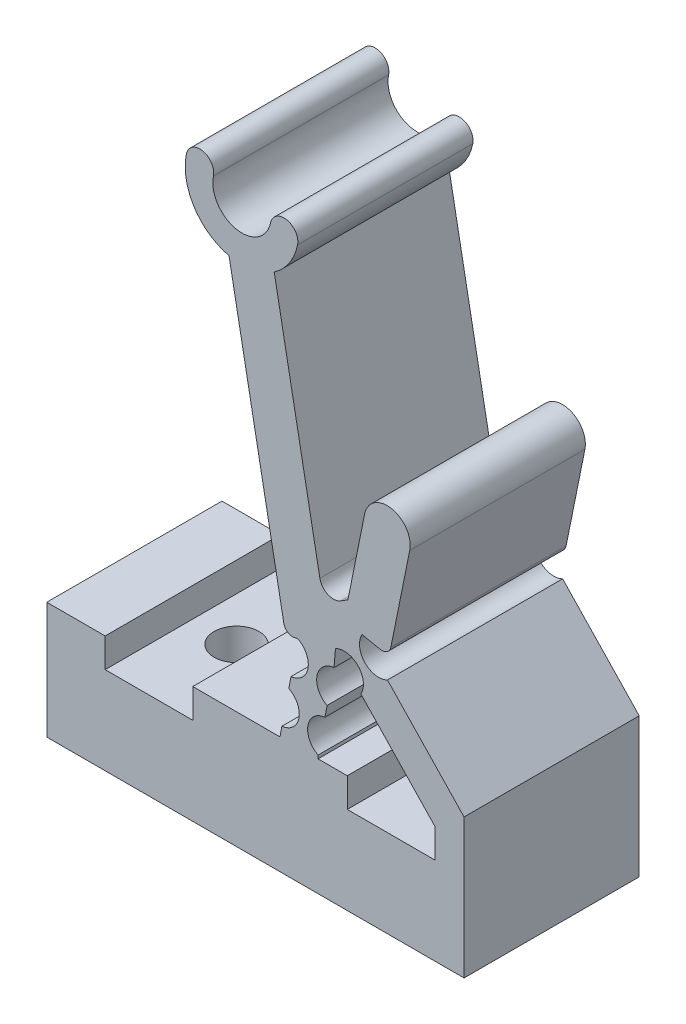
from build123d import *

# Parameters (mm, degrees)
BOSS_CONFIGUP_DEPTH       = 9.525
SKETCH2_W                 = 4.7625
SKETCH2_H                 = 9.525
CUT_NUTSLOT_DEPTH         = 1.5875
F_2_CLEARANCE_HOLE1_D     = 2.4384
F_2_CLEARANCE_HOLE1_DEPTH = 4.7625
FILLET1_R                 = 0.5
FILLET2_R                 = 0.75


with BuildPart() as part:
    # Sketch-ConfigUp → Boss-ConfigUp (new body)
    with BuildSketch(Plane.XY):
        with BuildLine():
            Line((6.777640655, 2.061684776), (6.65976118, 1.442811259))
            ThreePointArc((6.65976118, 1.442811259), (7.209405089, 0.320139636), (6.285540625, -0.521866571))
            Line((6.285540625, -0.521866571), (6.179869361, -1.076646329))
            Line((6.179869361, -1.076646329), (-6.50068369, -1.076646329))
            Line((-6.50068369, -1.076646329), (-6.50068369, -7.426646329))
            Line((-6.50068369, -7.426646329), (16.187718455, -7.426646329))
            Line((16.187718455, -7.426646329), (16.187718455, 0.156624326))
            Line((16.187718455, 0.156624326), (12.023957244, 4.524228201))
            ThreePointArc((12.023957244, 4.524228201), (10.791096024, 4.730512501), (10.643927811, 5.971818876))
            Line((10.643927811, 5.971818876), (12.11131272, 5.675127543))
            Line((12.11131272, 5.675127543), (13.234506428, 11.230252717))
            ThreePointArc((13.234506428, 11.230252717), (12.25702468, 12.703184973), (10.784092423, 11.725703225))
            Line((10.784092423, 11.725703225), (9.874535582, 7.227189683))
            Line((9.874535582, 7.227189683), (8.554573163, 6.384030216))
            Line((8.554573163, 6.384030216), (5.865715034, 20.656134447))
            ThreePointArc((5.865715034, 20.656134447), (6.685108796, 21.488679332), (7.136557001, 22.566051896))
            ThreePointArc((7.136557001, 22.566051896), (6.556251999, 23.453884146), (5.668419749, 22.873579144))
            ThreePointArc((5.668419749, 22.873579144), (3.78917482, 21.645266889), (2.560862565, 23.524511818))
            ThreePointArc((2.560862565, 23.524511818), (1.980557562, 24.412344068), (1.092725312, 23.832039065))
            ThreePointArc((1.092725312, 23.832039065), (1.51004236, 21.541118655), (3.408935798, 20.193278325))
            Line((3.408935798, 20.193278325), (6.478670085, 3.899533696))
            Line((6.478670085, 3.899533696), (7.151861209, 4.026362606))
            ThreePointArc((7.151861209, 4.026362606), (7.701505118, 2.903690983), (6.777640655, 2.061684776))
        make_face()
        with BuildLine():
            Line((8.742318485, 1.687464221), (8.62443901, 1.068590705))
            ThreePointArc((8.62443901, 1.068590705), (7.700574546, 0.226584498), (8.250218455, -0.896087126))
            Line((8.250218455, -0.896087126), (8.250218455, -1.076646329))
            Line((8.250218455, -1.076646329), (9.837718455, -1.076646329))
            Line((9.837718455, -1.076646329), (14.600218455, -1.076646329))
            Line((14.600218455, -1.076646329), (12.807260488, 0.804088365))
            Line((12.807260488, 0.804088365), (10.576366569, 3.144198768))
            ThreePointArc((10.576366569, 3.144198768), (10.429198356, 4.385505143), (9.196337136, 4.591789443))
            Line((9.196337136, 4.591789443), (9.11653904, 3.652142051))
            ThreePointArc((9.11653904, 3.652142051), (8.192674576, 2.810135844), (8.742318485, 1.687464221))
        make_face(mode=Mode.SUBTRACT)
    extrude(amount=BOSS_CONFIGUP_DEPTH)

    # Sketch2 → Cut-NutSlot (cut)
    with BuildSketch(Plane(origin=(0.004306068, -1.076646329, 0), x_dir=(-1, 0, 0), z_dir=(0, -1, 0))):
        with Locations((-12.214662387, -4.7625)):
            Rectangle(SKETCH2_W, SKETCH2_H)
        with Locations((0.948739758, -4.7625)):
            Rectangle(SKETCH2_W, SKETCH2_H)
    extrude(amount=CUT_NUTSLOT_DEPTH, mode=Mode.SUBTRACT)

    # 2 Clearance Hole1
    with Locations(Plane(origin=(0, -7.426646329, 0), x_dir=(-1, 0, 0), z_dir=(0, -1, 0))):
        with Locations((-12.218968455, -4.7625), (0.94443369, -4.7625)):
            Hole(F_2_CLEARANCE_HOLE1_D / 2, depth=F_2_CLEARANCE_HOLE1_DEPTH)

    # Fillet1
    fillet1_edges = [part.edges().sort_by_distance(p)[0] for p in [
        (6.478670085, 3.899533696, 4.7625),
        (12.11131272, 5.675127543, 4.7625),
    ]]
    fillet(fillet1_edges, radius=FILLET1_R)

    # Fillet2
    fillet2_edges = [part.edges().sort_by_distance(p)[0] for p in [
        (8.554573163, 6.384030216, 4.7625),
    ]]
    fillet(fillet2_edges, radius=FILLET2_R)


solid = part.part
